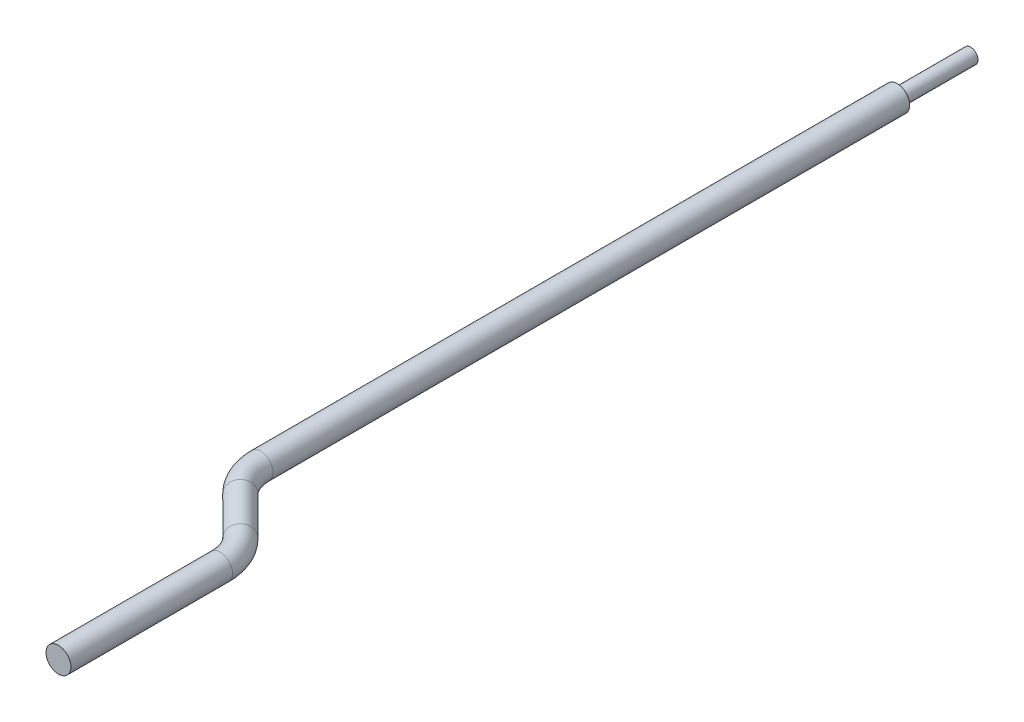
from build123d import *

# Parameters (mm, degrees)
SKETCH1_R           = 0.6477
BOSS_EXTRUDE1_DEPTH = 35.56
SKETCH3_R           = 0.6477
SKETCH4_R           = 0.6477
SKETCH4_R_2         = 0.381
CUT_EXTRUDE1_DEPTH  = 3.81


with BuildPart() as part:
    # Sketch1 → Boss-Extrude1 (new body)
    with BuildSketch(Plane.XY):
        Circle(SKETCH1_R)
    extrude(amount=BOSS_EXTRUDE1_DEPTH)

    # Sweep1: sweep along a path in Sketch2
    with BuildLine(Plane(origin=(0, 0, 0), x_dir=(1, 0, 0), z_dir=(0, 1, 0))) as sweep1_path:
        Line((3.4798, -50.8), (3.4798, -42.414004897))
        ThreePointArc((3.4798, -42.414004897), (3.286454013, -41.441988979), (2.735851224, -40.617953673))
        Line((2.735851224, -40.617953673), (0.743948776, -38.626051224))
        ThreePointArc((0.743948776, -38.626051224), (0.193345987, -37.802015918), (0, -36.83))
        Line((0, -36.83), (0, -35.56))
    # Sketch3 → Sweep1 (sweep)
    with BuildSketch(Plane.XY.offset(35.56)):
        Circle(SKETCH3_R)
    sweep(path=sweep1_path.line)

    # Sketch4 → Cut-Extrude1 (cut)
    with BuildSketch(Plane(origin=(0, 0, 0), x_dir=(-1, 0, 0), z_dir=(0, 0, -1))):
        Circle(SKETCH4_R)
        Circle(SKETCH4_R_2, mode=Mode.SUBTRACT)
    extrude(amount=-CUT_EXTRUDE1_DEPTH, mode=Mode.SUBTRACT)


solid = part.part
